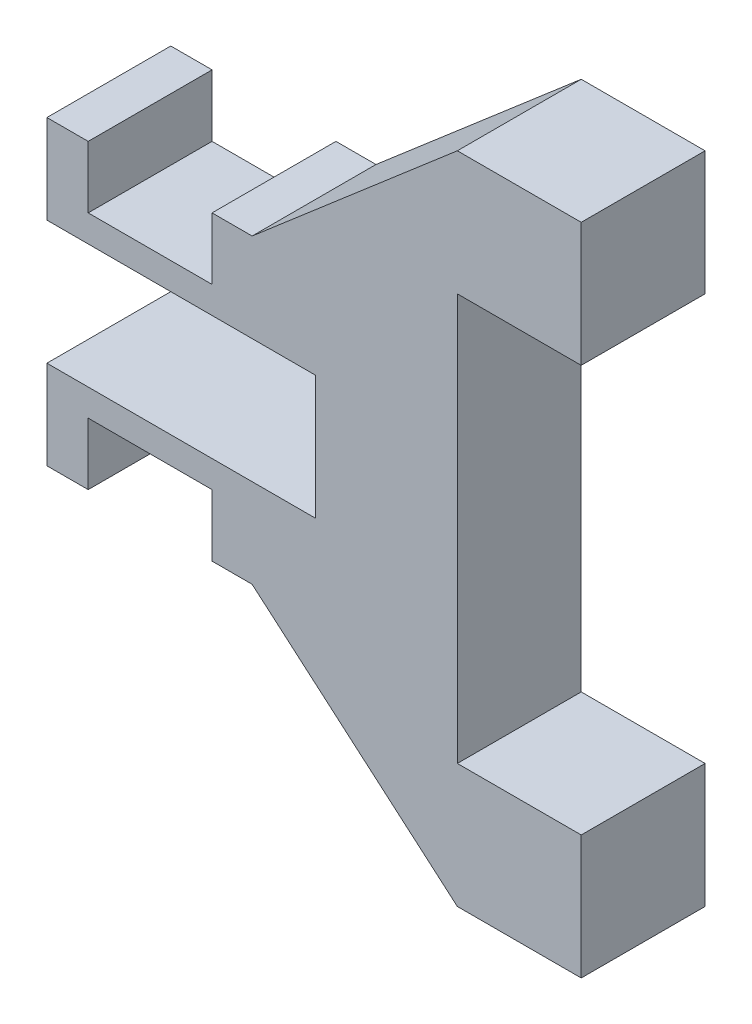
from build123d import *

# Parameters (mm, degrees)
BOSS_EXTRUDE1_DEPTH = 1.524
SKETCH3_W           = 1.524
SKETCH3_H           = 1.524
CUT_EXTRUDE1_DEPTH  = 0.762


with BuildPart() as part:
    # Sketch1 → Boss-Extrude1 (new body)
    with BuildSketch(Plane.XY):
        Polygon((57.718435694, 0), (57.718435694, -1.524), (54.412176394, -1.524), (54.412176394, -2.617357602), (56.936958373, -2.617357602), (59.461740351, -4.787750638), (60.985740351, -4.787750638), (60.985740351, -3.263750638), (59.461740351, -3.263750638), (59.461740351, 1.739750638), (60.985740351, 1.739750638), (60.985740351, 3.263750638), (59.461740351, 3.263750638), (56.936958373, 1.093357602), (54.412176394, 1.093357602), (54.412176394, 0), align=None)
    extrude(amount=BOSS_EXTRUDE1_DEPTH)

    # Sketch3 → Cut-Extrude1 (cut)
    with BuildSketch(Plane(origin=(0, 1.093357602, 0), x_dir=(1, 0, 0), z_dir=(0, 1, 0))):
        with Locations((55.682176394, -0.762)):
            Rectangle(SKETCH3_W, SKETCH3_H)
    cut_extrude1 = extrude(amount=-CUT_EXTRUDE1_DEPTH, mode=Mode.SUBTRACT)

    # Mirror1: Cut-Extrude1 across plane
    add(cut_extrude1.mirror(Plane.ZX.offset(-0.762)), mode=Mode.SUBTRACT)


solid = part.part
